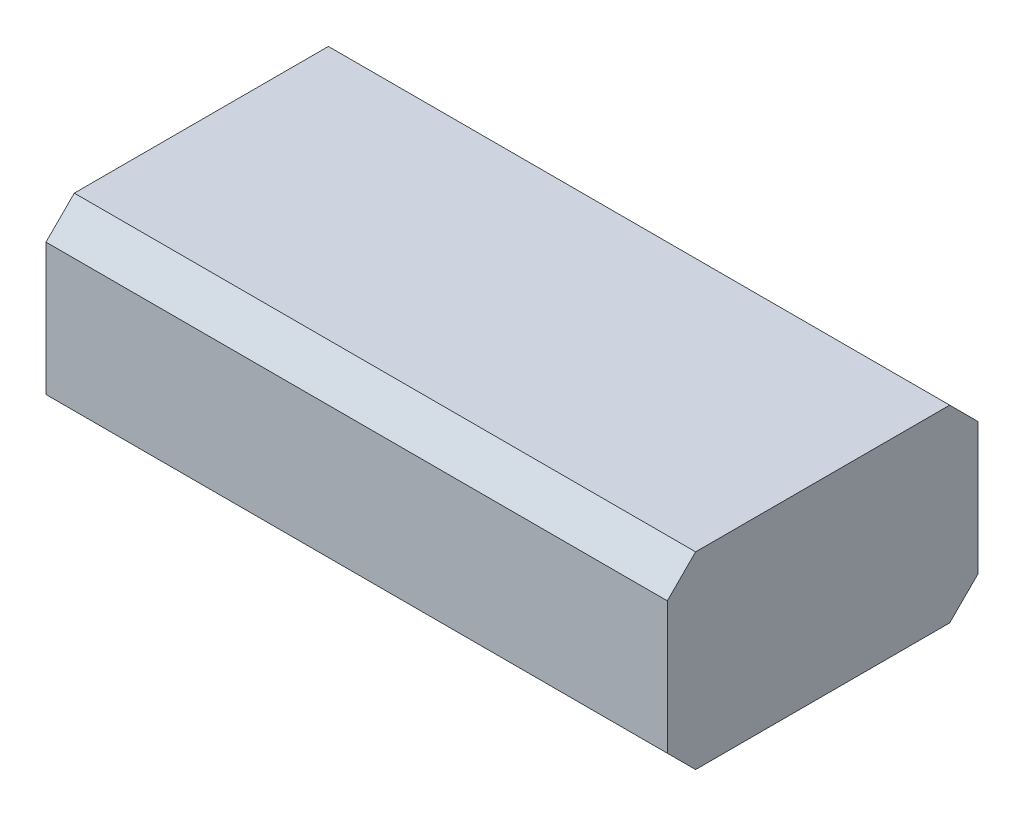
from build123d import *

# Parameters (mm, degrees)
SKETCH1_W           = 0.659
SKETCH1_H           = 0.2
BOSS_EXTRUDE1_DEPTH = 0.3295
CHAMFER1_SIZE       = 0.03


with BuildPart() as part:
    # Sketch1 → Boss-Extrude1 (new body)
    with BuildSketch(Plane.XY):
        with Locations((0.3295, 0.1)):
            Rectangle(SKETCH1_W, SKETCH1_H)
    extrude(amount=BOSS_EXTRUDE1_DEPTH)

    # Chamfer1
    chamfer1_edges = [part.edges().sort_by_distance(p)[0] for p in [
        (0.3295, 0.2, 0.3295),
        (0.3295, 0.2, 0),
        (0.3295, 0, 0),
        (0.3295, 0, 0.3295),
    ]]
    chamfer(chamfer1_edges, length=CHAMFER1_SIZE)


solid = part.part
